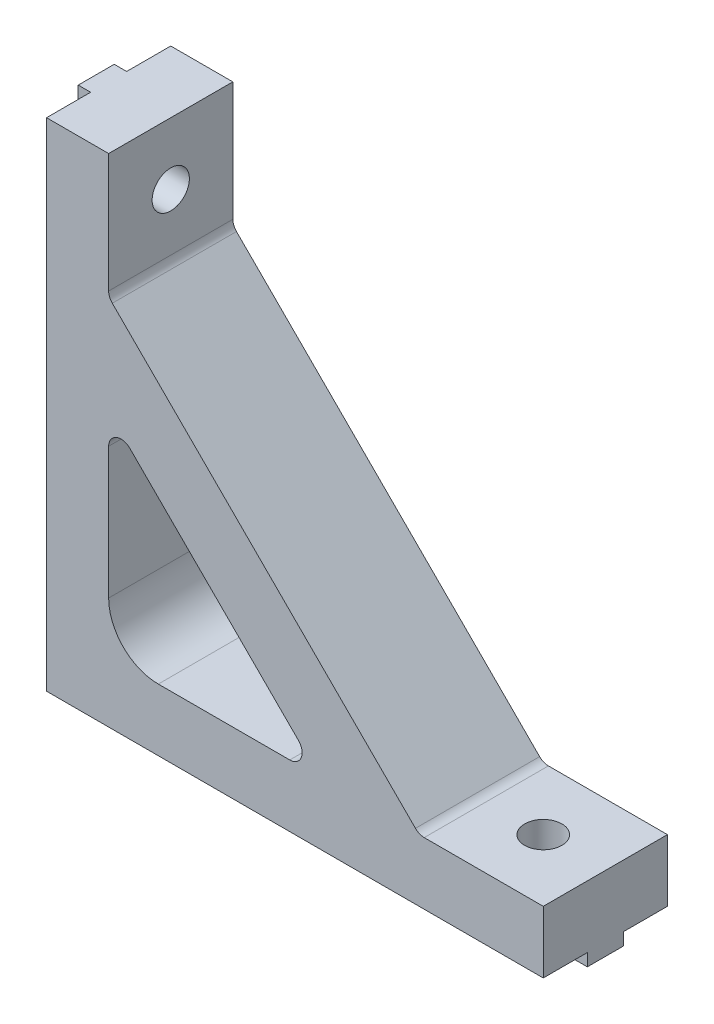
from build123d import *

# Parameters (mm, degrees)
MAIN_DEPTH                         = 10
ESQUISSE4_W                        = 2.9
ESQUISSE4_H                        = 40
MAKERBEAMFIXVERTICAL_DEPTH         = 1
MAKERBEAMVERTICALHOLE_DEPTH        = 58.445626465
MAKERBEAMVERTICALHOLE_DEPTH_BACK   = 58.445626465
ESQUISSE2_R                        = 1.5
ESQUISSE5_W                        = 40
ESQUISSE5_H                        = 2.9
MAKERBEAMFIXHORIZONTAL_DEPTH       = 1
MAKERBEAMHORIZONTALHOLE_DEPTH      = 58.445626465
MAKERBEAMHORIZONTALHOLE_DEPTH_BACK = 58.445626465
ESQUISSE3_R                        = 1.5
BOSS_EXTRUDE1_DEPTH                = 10
FILLET1_R                          = 1


with BuildPart() as part:
    # Esquisse1 → Main (new body)
    with BuildSketch(Plane.XY):
        with BuildLine():
            Line((0, 0), (40, 0))
            Line((40, 0), (40, 5))
            Line((40, 5), (9, 5))
            ThreePointArc((9, 5), (6.171572875, 6.171572875), (5, 9))
            Line((5, 9), (5, 40))
            Line((5, 40), (0, 40))
            Line((0, 40), (0, 0))
        make_face()
    extrude(amount=MAIN_DEPTH)

    # Esquisse4 → MakerBeamFixVertical (add)
    with BuildSketch(Plane.ZY):
        with Locations((5, 20)):
            Rectangle(ESQUISSE4_W, ESQUISSE4_H)
    extrude(amount=MAKERBEAMFIXVERTICAL_DEPTH)

    # Esquisse2 → MakerBeamVerticalHole (cut, two sides: drawn at the far end of the back side and taken through both)
    with BuildSketch(Plane.ZY.offset(-MAKERBEAMVERTICALHOLE_DEPTH_BACK)):
        with Locations(Location((5, 35, 0), (0, 0, 270))):
            Circle(ESQUISSE2_R)
    extrude(amount=MAKERBEAMVERTICALHOLE_DEPTH + MAKERBEAMVERTICALHOLE_DEPTH_BACK, mode=Mode.SUBTRACT)

    # Esquisse5 → MakerBeamFixHorizontal (add)
    with BuildSketch(Plane(origin=(0, 0, 0), x_dir=(-1, 0, 0), z_dir=(0, -1, 0))):
        with Locations((-20, -5)):
            Rectangle(ESQUISSE5_W, ESQUISSE5_H)
    extrude(amount=MAKERBEAMFIXHORIZONTAL_DEPTH)

    # Esquisse3 → MakerBeamHorizontalHole (cut, two sides: drawn at the far end of the back side and taken through both)
    with BuildSketch(Plane.XZ.offset(-MAKERBEAMHORIZONTALHOLE_DEPTH_BACK)):
        with Locations(Location((35, 5, 0), (0, 0, 255.164888418))):
            Circle(ESQUISSE3_R)
    extrude(amount=MAKERBEAMHORIZONTALHOLE_DEPTH + MAKERBEAMHORIZONTALHOLE_DEPTH_BACK, mode=Mode.SUBTRACT)

    # Sketch2 → Boss-Extrude1 (add)
    with BuildSketch(Plane.XY.offset(10)):
        Polygon((5, 30), (30, 5), (22, 5), (5, 22), align=None)
    extrude(amount=-BOSS_EXTRUDE1_DEPTH)

    # Fillet1
    fillet1_edges = [part.edges().sort_by_distance(p)[0] for p in [
        (5, 22, 5),
        (5, 30, 5),
        (30, 5, 5),
        (22, 5, 5),
    ]]
    fillet(fillet1_edges, radius=FILLET1_R)


solid = part.part
